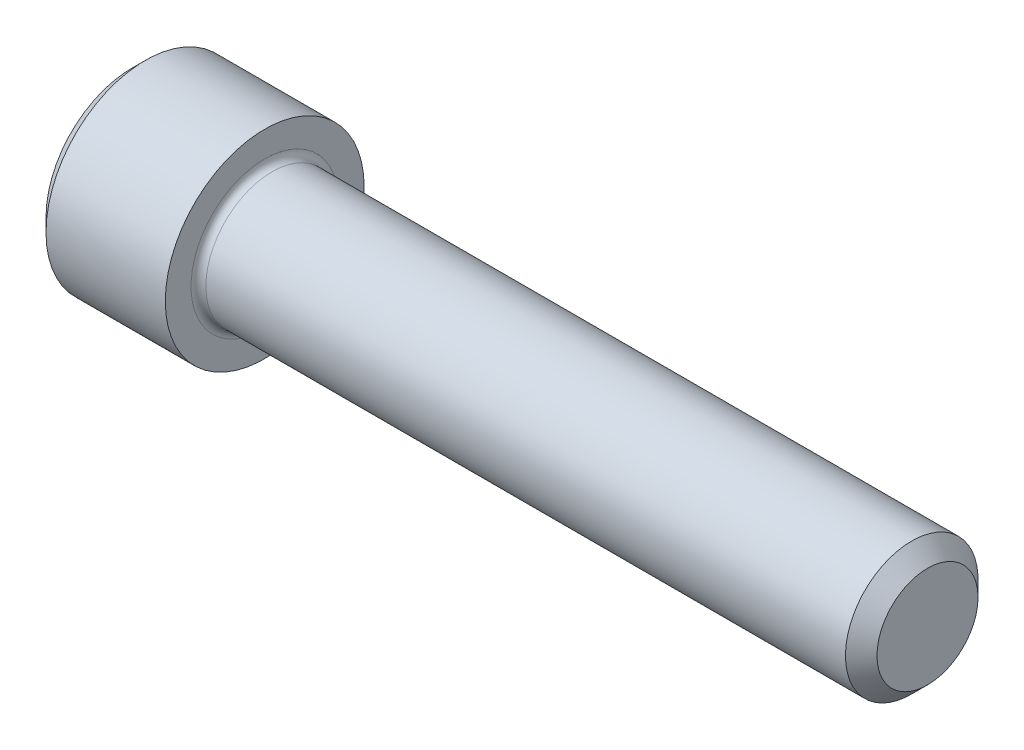
from build123d import *

# Parameters (mm, degrees)
FILLET1_R   = 0.3556
HEX_2_DEPTH = 3.048


with BuildPart() as part:
    # BodySke → Base-Revolve (revolve)
    with BuildSketch(Plane.XY):
        Polygon((0, 0), (0, 4.1275), (0.635, 4.7625), (6.35, 4.7625), (6.35, 3.175), (37.34435, 3.175), (38.1, 2.41935), (38.1, 0), align=None)
    revolve(axis=Axis((-31.75, 0, 0), (1, 0, 0)))

    # Fillet1
    fillet1_edges = [part.edges().sort_by_distance(p)[0] for p in [
        (6.35, -3.175, 0),
    ]]
    fillet(fillet1_edges, radius=FILLET1_R)

    # Sketch2 → Hex-PreBroach (revolve, cut)
    with BuildSketch(Plane.XY):
        Polygon((0, 2.38125), (3.048, 2.38125), (4.422815329, 0), (0, 0), align=None)
    revolve(axis=Axis((0, 0, 0), (1, 0, 0)), mode=Mode.SUBTRACT)

    # Sketch3 → Hex 2 (cut)
    with BuildSketch(Plane(origin=(0, 0, 0), x_dir=(0, 0.5, 0.866025404), z_dir=(-1, 0, 0))):
        Polygon((1.374815329, 2.38125), (-1.374815329, 2.38125), (-2.749630657, 0), (-1.374815329, -2.38125), (1.374815329, -2.38125), (2.749630657, 0), align=None)
    extrude(amount=-HEX_2_DEPTH, mode=Mode.SUBTRACT)


solid = part.part
